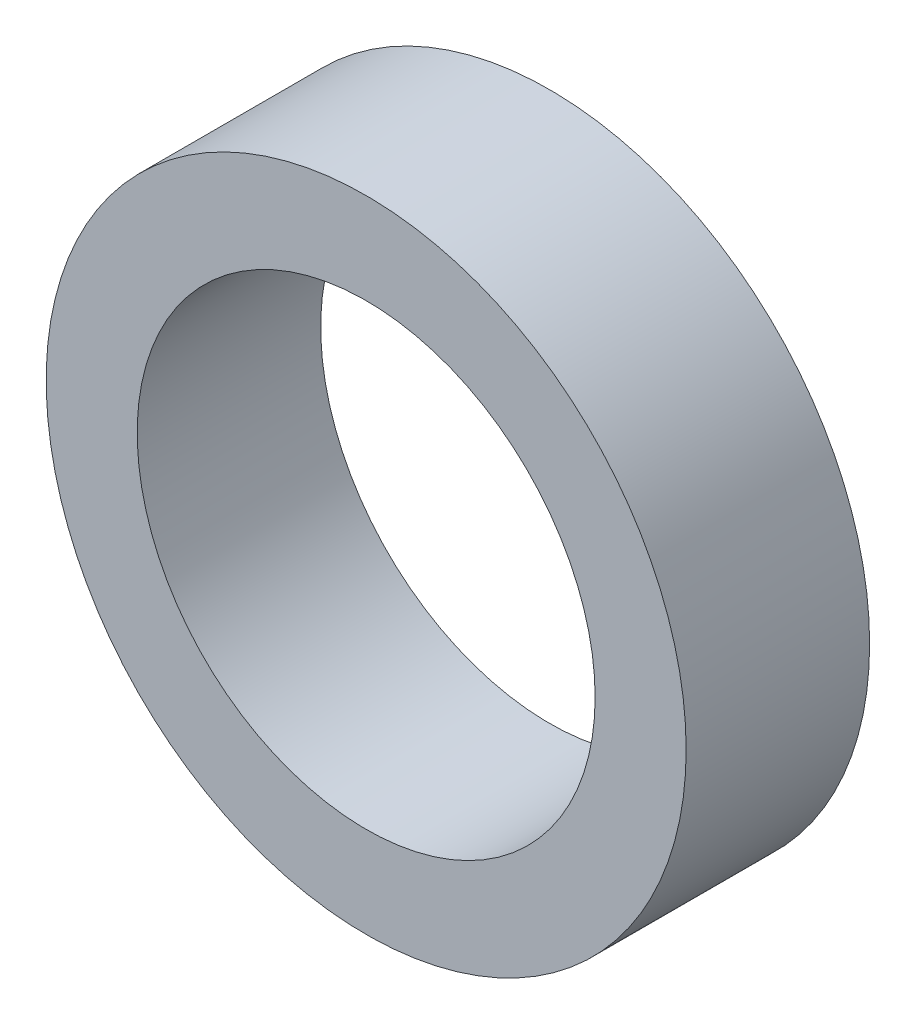
from build123d import *

# Parameters (mm, degrees)
SKETCH1_R           = 22.15
SKETCH1_R_2         = 15.85
BOSS_EXTRUDE1_DEPTH = 12.7


with BuildPart() as part:
    # Sketch1 → Boss-Extrude1 (new body)
    with BuildSketch(Plane.XY):
        Circle(SKETCH1_R)
        Circle(SKETCH1_R_2, mode=Mode.SUBTRACT)
    extrude(amount=BOSS_EXTRUDE1_DEPTH)


solid = part.part
